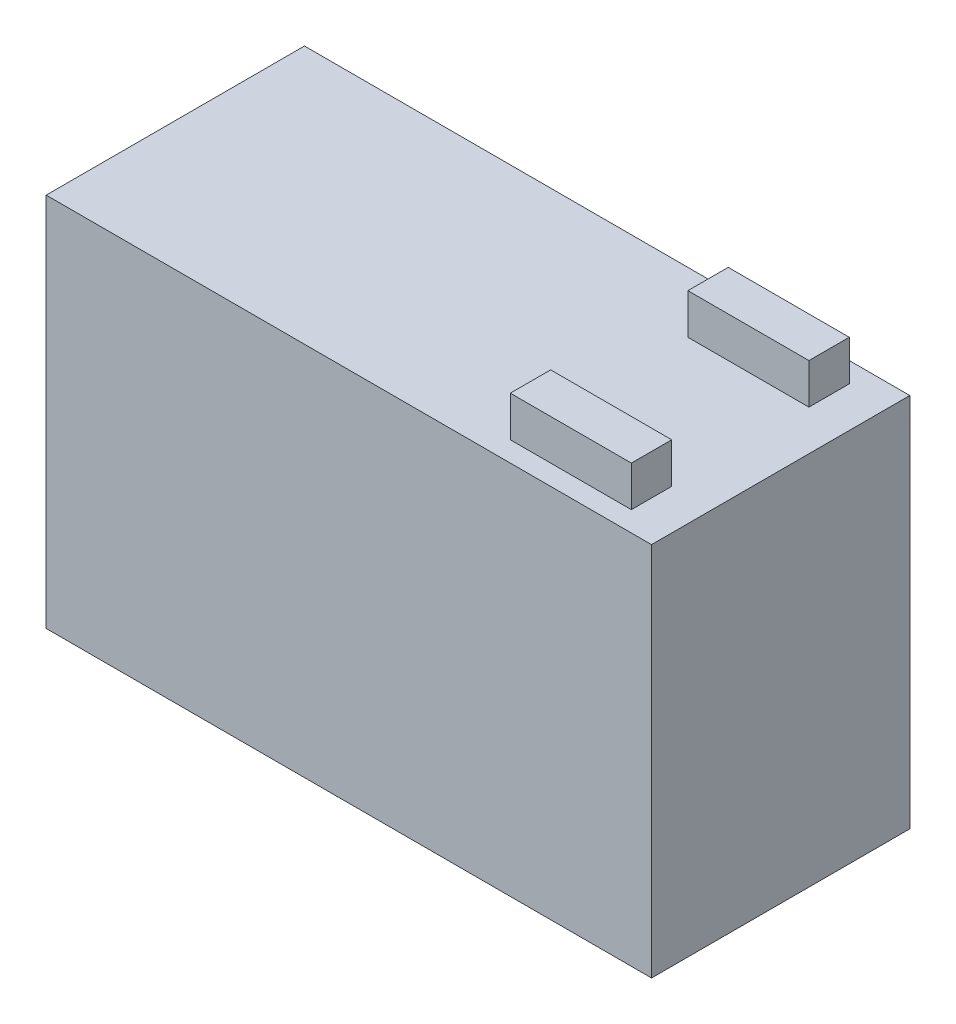
from build123d import *

# Parameters (mm, degrees)
ESQUISSE1_W        = 150
ESQUISSE1_H        = 64
BOSS_EXTRU_1_DEPTH = 93
ESQUISSE2_W        = 30
ESQUISSE2_H        = 10
BOSS_EXTRU_2_DEPTH = 10


with BuildPart() as part:
    # Esquisse1 → Boss.-Extru.1 (new body)
    with BuildSketch(Plane(origin=(0, 0, 0), x_dir=(1, 0, 0), z_dir=(0, 1, 0))):
        with Locations((40.269148016, 0)):
            Rectangle(ESQUISSE1_W, ESQUISSE1_H)
    extrude(amount=BOSS_EXTRU_1_DEPTH)

    # Esquisse2 → Boss.-Extru.2 (add)
    with BuildSketch(Plane(origin=(0, 93, 0), x_dir=(1, 0, 0), z_dir=(0, 1, 0))):
        with Locations((90.269148016, -22)):
            Rectangle(ESQUISSE2_W, ESQUISSE2_H)
    boss_extru_2 = extrude(amount=BOSS_EXTRU_2_DEPTH)

    # Symétrie1: Boss.-Extru.2 across plane
    add(boss_extru_2.mirror(Plane.XY))


solid = part.part
